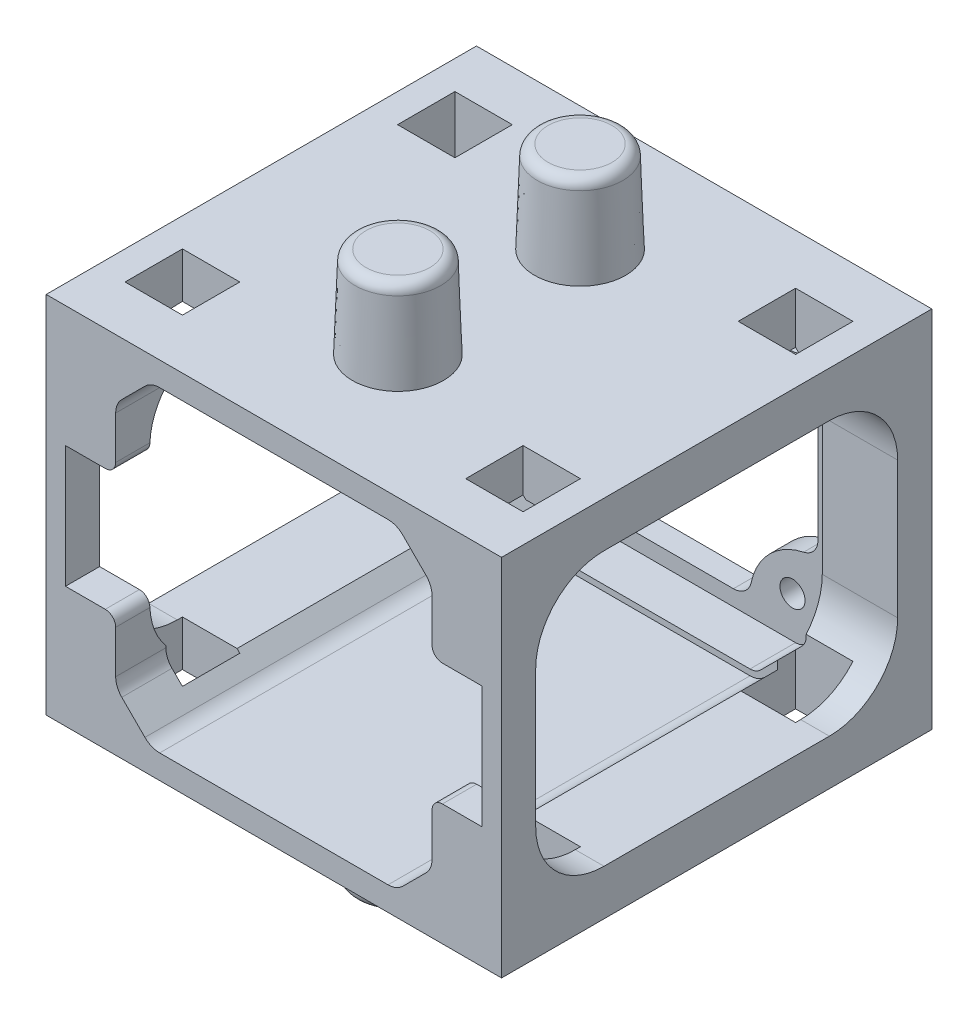
from build123d import *

# Parameters (mm, degrees)
SKETCH2_W                = 50.8
SKETCH2_H                = 50.8
BOSS_EXTRUDE1_DEPTH      = 6.35
SKETCH2_3_W              = 50.8
SKETCH2_3_H              = 50.8
SKETCH2_3_R              = 1.778
SKETCH2_3_R_2            = 1.75
BOSS_EXTRUDE2_DEPTH      = 3.175
SKETCH3_W                = 50.8
SKETCH3_H                = 50.8
BOSS_EXTRUDE3_DEPTH      = 50.475
SKETCH4_W                = 50.475
SKETCH4_H                = 38.1
CUT_EXTRUDE1_DEPTH       = 51.8
FILLET1_R                = 9.525
SKETCH5_W                = 60
SKETCH5_H                = 50.8
BOSS_EXTRUDE4_DEPTH      = 6.35
SKETCH6_W                = 60
SKETCH6_H                = 50.8
BOSS_EXTRUDE5_DEPTH      = 6.35
BOSS_EXTRUDE6_START      = 25.4
SKETCH10_R               = 6.35
BOSS_EXTRUDE6_DEPTH      = 12.7
BOSS_EXTRUDE6_TAPER      = 2
BOSS_EXTRUDE7_START      = -25.4
SKETCH10_2_R             = 6.35
BOSS_EXTRUDE7_DEPTH      = 12.7
BOSS_EXTRUDE7_TAPER      = 2
SKETCH11_W               = 8
SKETCH11_H               = 8
CUT_FOR_WIRES_DEPTH      = 13.7000001
CUT_FOR_WIRES_DEPTH_BACK = 64.5000001
SKETCH12_W               = 7
SKETCH12_H               = 17
CUT_EXTRUDE2_DEPTH       = 1
CUT_EXTRUDE2_DEPTH_BACK  = 4.7625
FILLET2_R                = 1.450000148
FILLET3_R                = 1.500000048


with BuildPart() as part:
    # Sketch2 → Boss-Extrude1 (new body)
    with BuildSketch(Plane.XY):
        Rectangle(SKETCH2_W, SKETCH2_H)
        with BuildLine():
            ThreePointArc((17.395081574, 20.622585227), (16.719453729, 21.07402532), (15.922496347, 21.23255))
            Line((15.922496347, 21.23255), (-15.922496347, 21.23255))
            ThreePointArc((-15.922496347, 21.23255), (-16.719453729, 21.07402532), (-17.395081574, 20.622585227))
            Line((-17.395081574, 20.622585227), (-20.622585227, 17.395081574))
            ThreePointArc((-20.622585227, 17.395081574), (-21.07402532, 16.719453729), (-21.23255, 15.922496347))
            Line((-21.23255, 15.922496347), (-21.23255, -15.922496347))
            ThreePointArc((-21.23255, -15.922496347), (-21.07402532, -16.719453729), (-20.622585227, -17.395081574))
            Line((-20.622585227, -17.395081574), (-17.395081574, -20.622585227))
            ThreePointArc((-17.395081574, -20.622585227), (-16.719453729, -21.07402532), (-15.922496347, -21.23255))
            Line((-15.922496347, -21.23255), (15.922496347, -21.23255))
            ThreePointArc((15.922496347, -21.23255), (16.719453729, -21.07402532), (17.395081574, -20.622585227))
            Line((17.395081574, -20.622585227), (20.622585227, -17.395081574))
            ThreePointArc((20.622585227, -17.395081574), (21.07402532, -16.719453729), (21.23255, -15.922496347))
            Line((21.23255, -15.922496347), (21.23255, 15.922496347))
            ThreePointArc((21.23255, 15.922496347), (21.07402532, 16.719453729), (20.622585227, 17.395081574))
            Line((20.622585227, 17.395081574), (17.395081574, 20.622585227))
        make_face(mode=Mode.SUBTRACT)
    extrude(amount=BOSS_EXTRUDE1_DEPTH)

    # Sketch2_3 → Boss-Extrude2 (add)
    with BuildSketch(Plane.XY):
        Rectangle(SKETCH2_3_W, SKETCH2_3_H)
        with BuildLine():
            ThreePointArc((17.395081574, 20.622585227), (16.719453729, 21.07402532), (15.922496347, 21.23255))
            Line((15.922496347, 21.23255), (-15.922496347, 21.23255))
            ThreePointArc((-15.922496347, 21.23255), (-16.719453729, 21.07402532), (-17.395081574, 20.622585227))
            Line((-17.395081574, 20.622585227), (-20.622585227, 17.395081574))
            ThreePointArc((-20.622585227, 17.395081574), (-21.07402532, 16.719453729), (-21.23255, 15.922496347))
            Line((-21.23255, 15.922496347), (-21.23255, -15.922496347))
            ThreePointArc((-21.23255, -15.922496347), (-21.07402532, -16.719453729), (-20.622585227, -17.395081574))
            Line((-20.622585227, -17.395081574), (-17.395081574, -20.622585227))
            ThreePointArc((-17.395081574, -20.622585227), (-16.719453729, -21.07402532), (-15.922496347, -21.23255))
            Line((-15.922496347, -21.23255), (15.922496347, -21.23255))
            ThreePointArc((15.922496347, -21.23255), (16.719453729, -21.07402532), (17.395081574, -20.622585227))
            Line((17.395081574, -20.622585227), (20.622585227, -17.395081574))
            ThreePointArc((20.622585227, -17.395081574), (21.07402532, -16.719453729), (21.23255, -15.922496347))
            Line((21.23255, -15.922496347), (21.23255, 15.922496347))
            ThreePointArc((21.23255, 15.922496347), (21.07402532, 16.719453729), (20.622585227, 17.395081574))
            Line((20.622585227, 17.395081574), (17.395081574, 20.622585227))
        make_face(mode=Mode.SUBTRACT)
        with BuildLine():
            Line((17.395081574, 20.622585227), (20.622585227, 17.395081574))
            ThreePointArc((20.622585227, 17.395081574), (21.07402532, 16.719453729), (21.23255, 15.922496347))
            Line((21.23255, 15.922496347), (21.23255, -15.922496347))
            ThreePointArc((21.23255, -15.922496347), (21.07402532, -16.719453729), (20.622585227, -17.395081574))
            Line((20.622585227, -17.395081574), (17.395081574, -20.622585227))
            ThreePointArc((17.395081574, -20.622585227), (16.719453729, -21.07402532), (15.922496347, -21.23255))
            Line((15.922496347, -21.23255), (-15.922496347, -21.23255))
            ThreePointArc((-15.922496347, -21.23255), (-16.719453729, -21.07402532), (-17.395081574, -20.622585227))
            Line((-17.395081574, -20.622585227), (-20.622585227, -17.395081574))
            ThreePointArc((-20.622585227, -17.395081574), (-21.07402532, -16.719453729), (-21.23255, -15.922496347))
            Line((-21.23255, -15.922496347), (-21.23255, 15.922496347))
            ThreePointArc((-21.23255, 15.922496347), (-21.07402532, 16.719453729), (-20.622585227, 17.395081574))
            Line((-20.622585227, 17.395081574), (-17.395081574, 20.622585227))
            ThreePointArc((-17.395081574, 20.622585227), (-16.719453729, 21.07402532), (-15.922496347, 21.23255))
            Line((-15.922496347, 21.23255), (15.922496347, 21.23255))
            ThreePointArc((15.922496347, 21.23255), (16.719453729, 21.07402532), (17.395081574, 20.622585227))
        make_face()
        with Locations((-15.5, 15.5)):
            Circle(SKETCH2_3_R, mode=Mode.SUBTRACT)
        with Locations((15.5, 15.5)):
            Circle(SKETCH2_3_R_2, mode=Mode.SUBTRACT)
        with Locations((15.5, -15.5)):
            Circle(SKETCH2_3_R_2, mode=Mode.SUBTRACT)
        with Locations((-15.5, -15.5)):
            Circle(SKETCH2_3_R_2, mode=Mode.SUBTRACT)
        with BuildLine():
            ThreePointArc((-19.05, -7.255398481), (-18.486085977, -8.851231871), (-17.044736842, -9.738472485))
            ThreePointArc((-17.044736842, -9.738472485), (-12.314807909, -12.314807909), (-9.738472485, -17.044736842))
            ThreePointArc((-9.738472485, -17.044736842), (-8.851231871, -18.486085977), (-7.255398481, -19.05))
            Line((-7.255398481, -19.05), (0, -19.05))
            Line((0, -19.05), (7.255398481, -19.05))
            ThreePointArc((7.255398481, -19.05), (8.851231871, -18.486085977), (9.738472485, -17.044736842))
            ThreePointArc((9.738472485, -17.044736842), (12.314807909, -12.314807909), (17.044736842, -9.738472485))
            ThreePointArc((17.044736842, -9.738472485), (18.486085977, -8.851231871), (19.05, -7.255398481))
            Line((19.05, -7.255398481), (19.05, 0))
            Line((19.05, 0), (19.05, 7.255398481))
            ThreePointArc((19.05, 7.255398481), (18.486085977, 8.851231871), (17.044736842, 9.738472485))
            ThreePointArc((17.044736842, 9.738472485), (12.314807909, 12.314807909), (9.738472485, 17.044736842))
            ThreePointArc((9.738472485, 17.044736842), (8.851231871, 18.486085977), (7.255398481, 19.05))
            Line((7.255398481, 19.05), (0, 19.05))
            Line((0, 19.05), (-7.255398481, 19.05))
            ThreePointArc((-7.255398481, 19.05), (-8.851231871, 18.486085977), (-9.738472485, 17.044736842))
            ThreePointArc((-9.738472485, 17.044736842), (-12.314807909, 12.314807909), (-17.044736842, 9.738472485))
            ThreePointArc((-17.044736842, 9.738472485), (-18.486085977, 8.851231871), (-19.05, 7.255398481))
            Line((-19.05, 7.255398481), (-19.05, 0))
            Line((-19.05, 0), (-19.05, -7.255398481))
        make_face(mode=Mode.SUBTRACT)
    extrude(amount=-BOSS_EXTRUDE2_DEPTH)

    # Sketch3 → Boss-Extrude3 (add)
    with BuildSketch(Plane.XY.offset(6.35)):
        Rectangle(SKETCH3_W, SKETCH3_H)
        with BuildLine():
            ThreePointArc((-21.206301875, 17.978798222), (-21.836687875, 17.035358902), (-22.05805, 15.922496347))
            Line((-22.05805, 15.922496347), (-22.05805, -15.922496347))
            ThreePointArc((-22.05805, -15.922496347), (-21.836687875, -17.035358902), (-21.206301875, -17.978798222))
            Line((-21.206301875, -17.978798222), (-17.978798222, -21.206301875))
            ThreePointArc((-17.978798222, -21.206301875), (-17.035358902, -21.836687875), (-15.922496347, -22.05805))
            Line((-15.922496347, -22.05805), (15.922496347, -22.05805))
            ThreePointArc((15.922496347, -22.05805), (17.035358902, -21.836687875), (17.978798222, -21.206301875))
            Line((17.978798222, -21.206301875), (21.206301875, -17.978798222))
            ThreePointArc((21.206301875, -17.978798222), (21.836687875, -17.035358902), (22.05805, -15.922496347))
            Line((22.05805, -15.922496347), (22.05805, 15.922496347))
            ThreePointArc((22.05805, 15.922496347), (21.836687875, 17.035358902), (21.206301875, 17.978798222))
            Line((21.206301875, 17.978798222), (17.978798222, 21.206301875))
            ThreePointArc((17.978798222, 21.206301875), (17.035358902, 21.836687875), (15.922496347, 22.05805))
            Line((15.922496347, 22.05805), (-15.922496347, 22.05805))
            ThreePointArc((-15.922496347, 22.05805), (-17.035358902, 21.836687875), (-17.978798222, 21.206301875))
            Line((-17.978798222, 21.206301875), (-21.206301875, 17.978798222))
        make_face(mode=Mode.SUBTRACT)
    extrude(amount=BOSS_EXTRUDE3_DEPTH)

    # Sketch4 → Cut-Extrude1 (cut, through all)
    with BuildSketch(Plane(origin=(25.4, 0, 0), x_dir=(0, 0, -1), z_dir=(1, 0, 0))):
        with Locations((-26.825, 0)):
            Rectangle(SKETCH4_W, SKETCH4_H)
    extrude(amount=-CUT_EXTRUDE1_DEPTH, mode=Mode.SUBTRACT)

    # Fillet1
    fillet1_edges = [part.edges().sort_by_distance(p)[0] for p in [
        (22.183833401, 19.05, 1.5875),
        (22.183833401, -19.05, 1.5875),
        (-22.183833401, 19.05, 1.5875),
        (-22.183833401, -19.05, 1.5875),
        (-22.767550048, -19.05, 52.0625),
        (-22.767550048, 19.05, 52.0625),
        (22.767550048, -19.05, 52.0625),
        (22.767550048, 19.05, 52.0625),
    ]]
    fillet(fillet1_edges, radius=FILLET1_R)

    # Sketch5 → Boss-Extrude4 (add)
    with BuildSketch(Plane(origin=(25.4, 0, 0), x_dir=(0, 0, -1), z_dir=(1, 0, 0))):
        with Locations((-26.825, 0)):
            Rectangle(SKETCH5_W, SKETCH5_H)
        with BuildLine():
            Line((-11.1125, 19.05), (-42.5375, 19.05))
            ThreePointArc((-42.5375, 19.05), (-49.272692091, 16.260192091), (-52.0625, 9.525))
            Line((-52.0625, 9.525), (-52.0625, -9.525))
            ThreePointArc((-52.0625, -9.525), (-49.272692091, -16.260192091), (-42.5375, -19.05))
            Line((-42.5375, -19.05), (-11.1125, -19.05))
            ThreePointArc((-11.1125, -19.05), (-4.377307909, -16.260192091), (-1.5875, -9.525))
            Line((-1.5875, -9.525), (-1.5875, 9.525))
            ThreePointArc((-1.5875, 9.525), (-4.377307909, 16.260192091), (-11.1125, 19.05))
        make_face(mode=Mode.SUBTRACT)
    extrude(amount=BOSS_EXTRUDE4_DEPTH)

    # Sketch6 → Boss-Extrude5 (add)
    with BuildSketch(Plane.ZY.offset(25.4)):
        with Locations((26.825, 0)):
            Rectangle(SKETCH6_W, SKETCH6_H)
        with BuildLine():
            Line((11.1125, -19.05), (42.5375, -19.05))
            ThreePointArc((42.5375, -19.05), (49.272692091, -16.260192091), (52.0625, -9.525))
            Line((52.0625, -9.525), (52.0625, 9.525))
            ThreePointArc((52.0625, 9.525), (49.272692091, 16.260192091), (42.5375, 19.05))
            Line((42.5375, 19.05), (11.1125, 19.05))
            ThreePointArc((11.1125, 19.05), (4.377307909, 16.260192091), (1.5875, 9.525))
            Line((1.5875, 9.525), (1.5875, -9.525))
            ThreePointArc((1.5875, -9.525), (4.377307909, -16.260192091), (11.1125, -19.05))
        make_face(mode=Mode.SUBTRACT)
    extrude(amount=BOSS_EXTRUDE5_DEPTH)

    # Sketch10 → Boss-Extrude6 (add)
    with BuildSketch(Plane(origin=(0, 0, 0), x_dir=(1, 0, 0), z_dir=(0, 1, 0)).offset(BOSS_EXTRUDE6_START)):
        with Locations((0, -14.125)):
            Circle(SKETCH10_R)
        with Locations((0, -39.525)):
            Circle(SKETCH10_R)
    extrude(amount=BOSS_EXTRUDE6_DEPTH, taper=BOSS_EXTRUDE6_TAPER)

    # Sketch10_2 → Boss-Extrude7 (add)
    with BuildSketch(Plane(origin=(0, 0, 0), x_dir=(1, 0, 0), z_dir=(0, 1, 0)).offset(BOSS_EXTRUDE7_START)):
        with Locations((0, -14.125)):
            Circle(SKETCH10_2_R)
        with Locations((0, -39.525)):
            Circle(SKETCH10_2_R)
    extrude(amount=-BOSS_EXTRUDE7_DEPTH, taper=BOSS_EXTRUDE7_TAPER)

    # Sketch11 → Cut for Wires (cut, two sides)
    with BuildSketch(Plane(origin=(0, -25.4, 0), x_dir=(-1, 0, 0), z_dir=(0, -1, 0))) as cut_for_wires_sk:
        with Locations((23.75, -7.825)):
            Rectangle(SKETCH11_W, SKETCH11_H)
        with Locations((23.75, -45.825)):
            Rectangle(SKETCH11_W, SKETCH11_H)
        with Locations((-23.75, -7.825)):
            Rectangle(SKETCH11_W, SKETCH11_H)
        with Locations((-23.75, -45.825)):
            Rectangle(SKETCH11_W, SKETCH11_H)
    extrude(amount=CUT_FOR_WIRES_DEPTH, mode=Mode.SUBTRACT)
    extrude(cut_for_wires_sk.sketch, amount=-CUT_FOR_WIRES_DEPTH_BACK, mode=Mode.SUBTRACT)

    # Sketch12 → Cut-Extrude2 (cut, two sides)
    with BuildSketch(Plane.XY.offset(56.825)) as cut_extrude2_sk:
        with Locations((-25.55805, 0)):
            Rectangle(SKETCH12_W, SKETCH12_H)
        with Locations((25.55805, 0)):
            Rectangle(SKETCH12_W, SKETCH12_H)
    extrude(amount=CUT_EXTRUDE2_DEPTH, mode=Mode.SUBTRACT)
    extrude(cut_extrude2_sk.sketch, amount=-CUT_EXTRUDE2_DEPTH_BACK, mode=Mode.SUBTRACT)

    # Fillet2
    fillet2_edges = [part.edges().sort_by_distance(p)[0] for p in [
        (-22.05805, 8.5, 54.44375),
        (-22.05805, -8.5, 54.44375),
        (22.05805, 8.5, 54.44375),
        (22.05805, -8.5, 54.44375),
    ]]
    fillet(fillet2_edges, radius=FILLET2_R)

    # Fillet3
    fillet3_edges = [part.edges().sort_by_distance(p)[0] for p in [
        (-5.906506227, 38.1, 14.125),
        (-5.906506227, 38.1, 39.525),
        (-5.906506227, -38.1, 14.125),
        (-5.906506227, -38.1, 39.525),
    ]]
    fillet(fillet3_edges, radius=FILLET3_R)


solid = part.part
